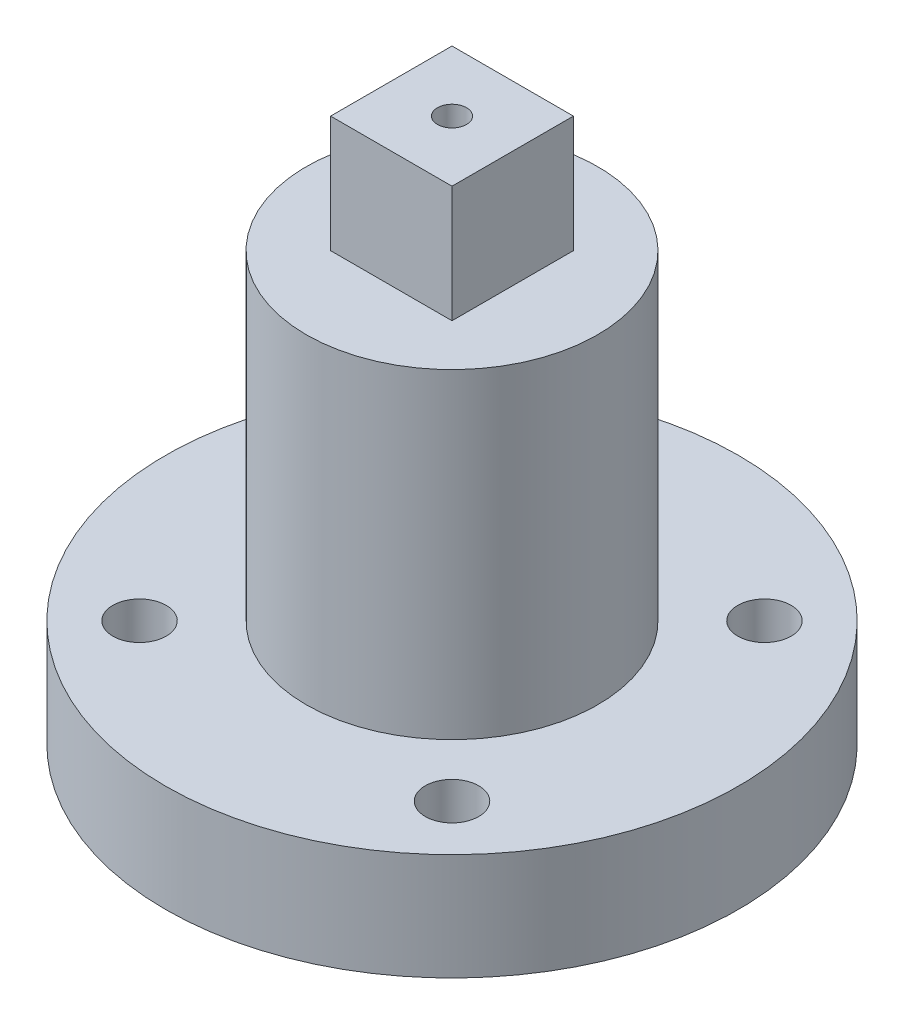
from build123d import *

# Parameters (mm, degrees)
SKETCH_1_R               = 29.5
EXTRUDE_1_DEPTH          = 11
SKETCH_2_R               = 15
EXTRUDE_2_DEPTH          = 33
SKETCH_3_W               = 12.5
SKETCH_3_H               = 12.5
EXTRUDE_3_DEPTH          = 12
SKETCH_4_R               = 2.75
CUT_EXTRUDE_1_DEPTH      = 12
PATTERN_CIRCULAR_1_COUNT = 4
SKETCH_5_R               = 1.5
CUT_EXTRUDE_2_DEPTH      = 10


with BuildPart() as part:
    # 草图1 → 凸台-拉伸1 (new body)
    with BuildSketch(Plane(origin=(0, 0, 0), x_dir=(1, 0, 0), z_dir=(0, 1, 0))):
        Circle(SKETCH_1_R)
    extrude(amount=EXTRUDE_1_DEPTH)

    # 草图2 → 凸台-拉伸2 (add)
    with BuildSketch(Plane(origin=(0, 11, 0), x_dir=(1, 0, 0), z_dir=(0, 1, 0))):
        Circle(SKETCH_2_R)
    extrude(amount=EXTRUDE_2_DEPTH)

    # 草图3 → 凸台-拉伸3 (add)
    with BuildSketch(Plane(origin=(0, 44, 0), x_dir=(1, 0, 0), z_dir=(0, 1, 0))):
        Rectangle(SKETCH_3_W, SKETCH_3_H)
    extrude(amount=EXTRUDE_3_DEPTH)

    # 草图4 → 切除-拉伸1 (cut)
    with BuildSketch(Plane(origin=(0, 11, 0), x_dir=(1, 0, 0), z_dir=(0, 1, 0))):
        with Locations((16.086679272, 16.086679272)):
            Circle(SKETCH_4_R)
    cut_extrude_1 = extrude(amount=-CUT_EXTRUDE_1_DEPTH, mode=Mode.SUBTRACT)

    # 阵列(圆周)1: 切除-拉伸1 ×4 about axis
    pattern_circular_1_axis = Axis((0, 0, 0), (0, 1, 0))
    for i in range(1, PATTERN_CIRCULAR_1_COUNT):
        add(cut_extrude_1.rotate(pattern_circular_1_axis, i * 360 / PATTERN_CIRCULAR_1_COUNT), mode=Mode.SUBTRACT)

    # 草图5 → 切除-拉伸2 (cut)
    with BuildSketch(Plane(origin=(0, 56, 0), x_dir=(1, 0, 0), z_dir=(0, 1, 0))):
        Circle(SKETCH_5_R)
    extrude(amount=-CUT_EXTRUDE_2_DEPTH, mode=Mode.SUBTRACT)


solid = part.part
